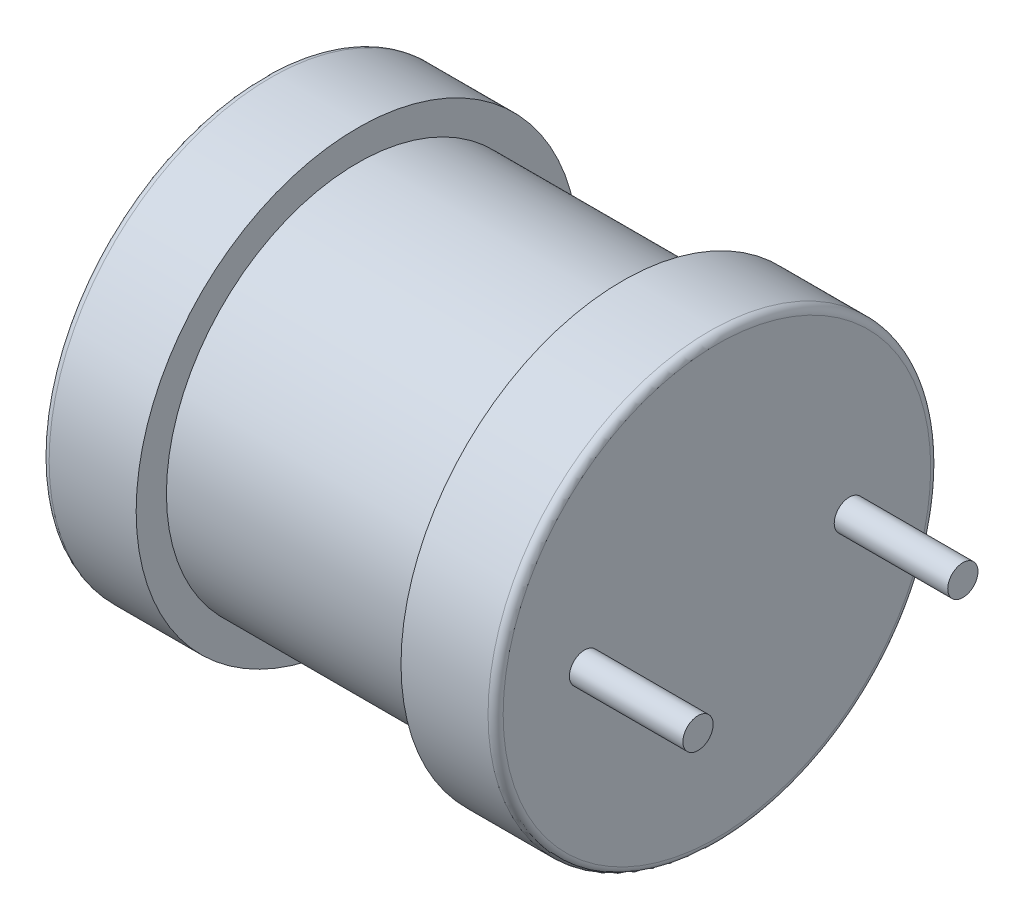
from build123d import *

# Parameters (mm, degrees)
SKETCH_2_R          = 0.4
EXTRUDE_2_DEPTH     = 3
CUT_EXTRUDE_1_DEPTH = 0.2


with BuildPart() as part:
    # Эскиз1 → Повернуть1 (revolve)
    with BuildSketch(Plane.XY):
        with BuildLine():
            Line((0, 0), (0, 5.65))
            ThreePointArc((0, 5.65), (0.058578644, 5.791421356), (0.2, 5.85))
            Line((0.2, 5.85), (2.5, 5.85))
            Line((2.5, 5.85), (2.5, 5.05))
            Line((2.5, 5.05), (9.5, 5.05))
            Line((9.5, 5.05), (9.5, 5.85))
            Line((9.5, 5.85), (11.8, 5.85))
            ThreePointArc((11.8, 5.85), (11.941421356, 5.791421356), (12, 5.65))
            Line((12, 5.65), (12, 0))
            Line((12, 0), (0, 0))
        make_face()
    revolve(axis=Axis((-21.888516746, 0, 0), (1, 0, 0)))

    # Эскиз2 → Бобышка-Вытянуть2 (add)
    with BuildSketch(Plane(origin=(12, 0, 0), x_dir=(0, 0, -1), z_dir=(1, 0, 0))):
        with Locations((3.5, 0)):
            Circle(SKETCH_2_R)
        with Locations((-3.5, 0)):
            Circle(SKETCH_2_R)
    extrude(amount=EXTRUDE_2_DEPTH)

    # Эскиз4 → Вырез-Вытянуть1 (cut)
    with BuildSketch(Plane.ZY):
        with BuildLine():
            Line((-3.579982895, -0.442704628), (-3.579982895, 1.098286583))
            Line((-3.579982895, 1.098286583), (-2.911355699, 1.098286583))
            add(Edge.make_bspline(
                [(-2.911355699, 1.098286583), (-2.895611576, 1.098163221), (-2.865140669, 1.097924469), (-2.820951561, 1.096234375), (-2.779705459, 1.092590975), (-2.741326525, 1.088651146), (-2.705821577, 1.082604034), (-2.673227246, 1.075668134), (-2.643493207, 1.067414308), (-2.61648653, 1.057665903), (-2.591430224, 1.046637043), (-2.56820492, 1.033029211), (-2.545845173, 1.018117929), (-2.525180832, 1.000599397), (-2.505666872, 0.981418226), (-2.487321379, 0.960313785), (-2.470415944, 0.937102929), (-2.449565115, 0.903883382), (-2.427196426, 0.85964194), (-2.408559795, 0.803022481), (-2.396543229, 0.74379646), (-2.395257422, 0.703322335), (-2.394605041, 0.682786949)],
                knots=[0, 0, 0, 0, 4.7234e-05, 9.1416e-05, 0.000132612, 0.00017144, 0.000207116, 0.000240599, 0.000271383, 0.000299603, 0.000326683, 0.00035337, 0.000380255, 0.00040721, 0.000434496, 0.000462287, 0.000490997, 0.000520544, 0.000579907, 0.00063916, 0.000698913, 0.000760455, 0.000760455, 0.000760455, 0.000760455], degree=3))
            add(Edge.make_bspline(
                [(-2.394605041, 0.682786949), (-2.394906586, 0.669605063), (-2.395502158, 0.643569933), (-2.400064303, 0.605291323), (-2.408319136, 0.568717651), (-2.418904333, 0.533528611), (-2.433392237, 0.500222775), (-2.450175846, 0.468119861), (-2.47096835, 0.438101822), (-2.494247858, 0.409369326), (-2.520943212, 0.382537746), (-2.551289248, 0.358575099), (-2.584985155, 0.337020651), (-2.622189626, 0.318469096), (-2.662474401, 0.301512094), (-2.706344942, 0.287857499), (-2.753624192, 0.276707475), (-2.786400366, 0.271308203), (-2.803313447, 0.268522084)],
                knots=[0, 0, 0, 0, 3.9543e-05, 7.81e-05, 0.000115399, 0.000151916, 0.000188153, 0.000224197, 0.000260414, 0.00029749, 0.000335033, 0.000373698, 0.00041326, 0.000454814, 0.000498268, 0.000544251, 0.00059247, 0.000643881, 0.000643881, 0.000643881, 0.000643881], degree=3))
            add(Edge.make_bspline(
                [(-2.803313447, 0.268522084), (-2.790907062, 0.262254652), (-2.767346889, 0.250352573), (-2.734727539, 0.231690216), (-2.707077245, 0.212621886), (-2.691058028, 0.198983656), (-2.683540893, 0.192583816)],
                knots=[0, 0, 0, 0, 4.1695e-05, 7.9181e-05, 0.000112663, 0.000142267, 0.000142267, 0.000142267, 0.000142267], degree=3))
            add(Edge.make_bspline(
                [(-2.683540893, 0.192583816), (-2.668983535, 0.178313351), (-2.639081689, 0.149000804), (-2.597875646, 0.099072948), (-2.557924972, 0.043495584), (-2.533651926, 0.003329634), (-2.521168822, -0.017326846)],
                knots=[0, 0, 0, 0, 6.1119e-05, 0.000125544, 0.000193904, 0.000266284, 0.000266284, 0.000266284, 0.000266284], degree=3))
            Line((-2.521168822, -0.017326846), (-2.268349952, -0.442704628))
            Line((-2.268349952, -0.442704628), (-2.517464516, -0.442704628))
            Line((-2.517464516, -0.442704628), (-2.709471033, -0.117343103))
            add(Edge.make_bspline(
                [(-2.709471033, -0.117343103), (-2.716374623, -0.105927402), (-2.729752647, -0.08380565), (-2.749076723, -0.051497895), (-2.768023344, -0.021753459), (-2.785596011, 0.00627777), (-2.802507852, 0.0320869), (-2.81859546, 0.055763585), (-2.833416095, 0.077618434), (-2.851773368, 0.103063166), (-2.873138185, 0.131217997), (-2.898069461, 0.160212157), (-2.921811427, 0.183328815), (-2.951050096, 0.205997157), (-2.987266612, 0.22719958), (-3.018051334, 0.236941511), (-3.032980406, 0.241665867)],
                knots=[0, 0, 0, 0, 4.0023e-05, 7.7558e-05, 0.00011293, 0.000145815, 0.000176809, 0.000205491, 0.000231692, 0.000256022, 0.000299612, 0.000337683, 0.000370649, 0.000398806, 0.000448581, 0.000495448, 0.000495448, 0.000495448, 0.000495448], degree=3))
            add(Edge.make_bspline(
                [(-3.032980406, 0.241665867), (-3.039244092, 0.242795423), (-3.053544273, 0.245374232), (-3.077825946, 0.247058456), (-3.107246172, 0.248846034), (-3.128567511, 0.24879395), (-3.140096582, 0.248765787)],
                knots=[0, 0, 0, 0, 1.9082e-05, 4.3564e-05, 7.293e-05, 0.000107505, 0.000107505, 0.000107505, 0.000107505], degree=3))
            Line((-3.140096582, 0.248765787), (-3.362663622, 0.248765787))
            Line((-3.362663622, 0.248765787), (-3.362663622, -0.442704628))
            Line((-3.362663622, -0.442704628), (-3.579982895, -0.442704628))
        make_face()
        with BuildLine():
            Line((-3.362663622, 0.426572465), (-2.949942218, 0.426572465))
            add(Edge.make_bspline(
                [(-2.949942218, 0.426572465), (-2.929246803, 0.426896264), (-2.890558667, 0.427501577), (-2.836459429, 0.43267031), (-2.790354841, 0.440883647), (-2.751333481, 0.45286376), (-2.718549379, 0.469496136), (-2.690036423, 0.489765794), (-2.666341798, 0.51515565), (-2.646630317, 0.543802698), (-2.631308179, 0.575327343), (-2.620255519, 0.608439362), (-2.613021361, 0.642860467), (-2.612293235, 0.666286996), (-2.611924314, 0.678156567)],
                knots=[0, 0, 0, 0, 6.2075e-05, 0.000116043, 0.000162843, 0.000202381, 0.000237999, 0.0002727, 0.000306763, 0.000341612, 0.000376678, 0.000411528, 0.000446156, 0.000481721, 0.000481721, 0.000481721, 0.000481721], degree=3))
            add(Edge.make_bspline(
                [(-2.611924314, 0.678156567), (-2.612211135, 0.686806375), (-2.612772932, 0.703748808), (-2.615718061, 0.728615596), (-2.621444089, 0.752244792), (-2.629005296, 0.774761303), (-2.639108603, 0.796000211), (-2.651110919, 0.816126096), (-2.665433388, 0.83502741), (-2.681838952, 0.85276173), (-2.70067552, 0.868898229), (-2.72219131, 0.882820527), (-2.746216626, 0.894651477), (-2.772779396, 0.90404131), (-2.801795941, 0.911551647), (-2.833431446, 0.916548033), (-2.867541235, 0.920163401), (-2.891177341, 0.920372432), (-2.903329703, 0.920479904)],
                knots=[0, 0, 0, 0, 2.596e-05, 5.0847e-05, 7.4957e-05, 9.8776e-05, 0.000121975, 0.000145375, 0.000168959, 0.000192986, 0.000217729, 0.000243158, 0.000269664, 0.000297884, 0.000327533, 0.000359454, 0.000393887, 0.000430324, 0.000430324, 0.000430324, 0.000430324], degree=3))
            Line((-2.903329703, 0.920479904), (-3.362663622, 0.920479904))
            Line((-3.362663622, 0.920479904), (-3.362663622, 0.426572465))
        make_face(mode=Mode.SUBTRACT)
        Polygon((-2.038991684, -0.442704628), (-2.038991684, 1.098286583), (-1.821672411, 1.098286583), (-1.821672411, -0.26489795), (-1.090689401, -0.26489795), (-1.090689401, -0.442704628), align=None)
        with BuildLine():
            Line((-0.85361383, -0.442704628), (-0.85361383, 1.098286583))
            Line((-0.85361383, 1.098286583), (-0.276668202, 1.098286583))
            add(Edge.make_bspline(
                [(-0.276668202, 1.098286583), (-0.262360905, 1.098231696), (-0.2344433, 1.098124598), (-0.193677825, 1.095446171), (-0.155069876, 1.091782639), (-0.118536339, 1.087060233), (-0.084235294, 1.080208119), (-0.052198707, 1.071907241), (-0.022259858, 1.062332445), (0.014335821, 1.047746931), (0.05650833, 1.025296724), (0.101679093, 0.991797473), (0.140979412, 0.951576888), (0.173317795, 0.905461711), (0.199961135, 0.856202004), (0.218850951, 0.804736212), (0.230928234, 0.752184871), (0.232298542, 0.716600837), (0.232982537, 0.698838941)],
                knots=[0, 0, 0, 0, 4.2913e-05, 8.3735e-05, 0.000122499, 0.000159258, 0.000194189, 0.000227357, 0.000258499, 0.000288421, 0.000345456, 0.000401268, 0.000456497, 0.000513374, 0.000569719, 0.000624023, 0.000677427, 0.000730651, 0.000730651, 0.000730651, 0.000730651], degree=3))
            add(Edge.make_bspline(
                [(0.232982537, 0.698838941), (0.232263514, 0.682313906), (0.230832401, 0.649423154), (0.219442343, 0.600973075), (0.201465346, 0.55392835), (0.176045364, 0.508860901), (0.143555441, 0.466595227), (0.103277214, 0.428561358), (0.055789477, 0.394677783), (0.020149932, 0.376616841), (0.001772117, 0.367303572)],
                knots=[0, 0, 0, 0, 4.9529e-05, 9.8581e-05, 0.000148514, 0.000200205, 0.000253244, 0.000307829, 0.000365819, 0.000427558, 0.000427558, 0.000427558, 0.000427558], degree=3))
            add(Edge.make_bspline(
                [(0.001772117, 0.367303572), (0.013140755, 0.363744701), (0.035398615, 0.356777036), (0.067396601, 0.344027187), (0.097432938, 0.329509659), (0.125573005, 0.313200596), (0.151626666, 0.294948968), (0.175520404, 0.274726321), (0.197419891, 0.252845596), (0.217285999, 0.229320103), (0.234736291, 0.204301233), (0.250387023, 0.178335799), (0.263310717, 0.151111121), (0.273903798, 0.122697881), (0.282167976, 0.093271648), (0.288102555, 0.062719243), (0.291485114, 0.031111784), (0.291993163, 0.009640192), (0.29225143, -0.001274854)],
                knots=[0, 0, 0, 0, 3.5728e-05, 6.995e-05, 0.000103223, 0.000135731, 0.000167418, 0.000198524, 0.00022952, 0.000260191, 0.000290765, 0.000320942, 0.000351042, 0.000381029, 0.000411814, 0.000442629, 0.000474298, 0.000507043, 0.000507043, 0.000507043, 0.000507043], degree=3))
            add(Edge.make_bspline(
                [(0.29225143, -0.001274854), (0.291719104, -0.018798809), (0.290663969, -0.053533419), (0.282190063, -0.104656925), (0.267869609, -0.153833428), (0.248158724, -0.200267805), (0.22467241, -0.243203222), (0.197979392, -0.281515492), (0.168760396, -0.314810382), (0.136192645, -0.342817336), (0.100486217, -0.366587044), (0.060632609, -0.386602693), (0.016939963, -0.404254577), (-0.03147975, -0.418355553), (-0.084604489, -0.429557351), (-0.143155205, -0.436835177), (-0.207221854, -0.442045124), (-0.25185787, -0.44247865), (-0.275124741, -0.442704628)],
                knots=[0, 0, 0, 0, 5.2551e-05, 0.000104163, 0.000154961, 0.000205872, 0.000255194, 0.000301524, 0.000345694, 0.000387714, 0.000430009, 0.000474049, 0.000521283, 0.000571193, 0.000625136, 0.000683987, 0.000748077, 0.000817859, 0.000817859, 0.000817859, 0.000817859], degree=3))
            Line((-0.275124741, -0.442704628), (-0.85361383, -0.442704628))
        make_face()
        with BuildLine():
            Line((-0.636294557, 0.446328763), (-0.318650335, 0.446328763))
            add(Edge.make_bspline(
                [(-0.318650335, 0.446328763), (-0.308256225, 0.446369886), (-0.288286792, 0.446448892), (-0.259481361, 0.44755048), (-0.232895329, 0.448490293), (-0.208631534, 0.450849149), (-0.186569771, 0.453159544), (-0.16679833, 0.456269696), (-0.149220367, 0.459774132), (-0.138457378, 0.463024759), (-0.133435045, 0.464541599)],
                knots=[0, 0, 0, 0, 3.1179e-05, 5.9903e-05, 8.6479e-05, 0.000110961, 0.000133017, 0.000153013, 0.000170994, 0.000186725, 0.000186725, 0.000186725, 0.000186725], degree=3))
            add(Edge.make_bspline(
                [(-0.133435045, 0.464541599), (-0.121634362, 0.46867538), (-0.098885116, 0.476644442), (-0.068398997, 0.494742985), (-0.042433686, 0.516461148), (-0.021058762, 0.542182421), (-0.004633193, 0.571769154), (0.007545893, 0.60460779), (0.014214212, 0.641157382), (0.015167116, 0.66650324), (0.015663264, 0.679700028)],
                knots=[0, 0, 0, 0, 3.7433e-05, 7.2164e-05, 0.00010568, 0.000138565, 0.000171876, 0.000206742, 0.000243189, 0.000282778, 0.000282778, 0.000282778, 0.000282778], degree=3))
            add(Edge.make_bspline(
                [(0.015663264, 0.679700028), (0.015264328, 0.692382994), (0.014486848, 0.717100634), (0.007960599, 0.752994932), (-0.003332832, 0.786387984), (-0.018627232, 0.817272467), (-0.037994005, 0.844748651), (-0.061108924, 0.868371737), (-0.088798966, 0.88622975), (-0.114680862, 0.897369615), (-0.137959575, 0.904338652), (-0.158758288, 0.908461944), (-0.182350232, 0.912094974), (-0.208813041, 0.915183656), (-0.238156726, 0.917580758), (-0.2704717, 0.919485096), (-0.305681039, 0.920293632), (-0.330071756, 0.920416268), (-0.342728322, 0.920479904)],
                knots=[0, 0, 0, 0, 3.8031e-05, 7.4117e-05, 0.000108967, 0.000143479, 0.00017714, 0.000209445, 0.000241979, 0.000275298, 0.000293659, 0.000314788, 0.000338845, 0.000365264, 0.000394694, 0.00042716, 0.000462363, 0.000500333, 0.000500333, 0.000500333, 0.000500333], degree=3))
            Line((-0.342728322, 0.920479904), (-0.636294557, 0.920479904))
            Line((-0.636294557, 0.920479904), (-0.636294557, 0.446328763))
        make_face(mode=Mode.SUBTRACT)
        with BuildLine():
            Line((-0.636294557, -0.26489795), (-0.271729128, -0.26489795))
            add(Edge.make_bspline(
                [(-0.271729128, -0.26489795), (-0.257220265, -0.264731264), (-0.23056348, -0.264425015), (-0.194102207, -0.263464298), (-0.164630226, -0.261117625), (-0.147420146, -0.258590858), (-0.13991758, -0.257489338)],
                knots=[0, 0, 0, 0, 4.353e-05, 7.9977e-05, 0.000109406, 0.000132151, 0.000132151, 0.000132151, 0.000132151], degree=3))
            add(Edge.make_bspline(
                [(-0.13991758, -0.257489338), (-0.129161127, -0.255228441), (-0.108333853, -0.250850759), (-0.078972393, -0.24108023), (-0.052051647, -0.229887567), (-0.028041475, -0.215662937), (-0.005808631, -0.199270025), (0.013513364, -0.178794493), (0.03130984, -0.155530823), (0.046728919, -0.128908198), (0.059197483, -0.099456481), (0.068726993, -0.067630723), (0.073803104, -0.033542511), (0.074550494, -0.010139103), (0.074932156, 0.001812067)],
                knots=[0, 0, 0, 0, 3.2948e-05, 6.3795e-05, 9.2696e-05, 0.000120226, 0.00014733, 0.000175273, 0.000204352, 0.000235061, 0.000267284, 0.000300105, 0.000334464, 0.00037032, 0.00037032, 0.00037032, 0.00037032], degree=3))
            add(Edge.make_bspline(
                [(0.074932156, 0.001812067), (0.074506944, 0.015843457), (0.073677735, 0.0432061), (0.065795828, 0.082746504), (0.052776206, 0.119420721), (0.034448373, 0.15272085), (0.011968328, 0.182671448), (-0.015230256, 0.208077725), (-0.046944005, 0.228238863), (-0.083270389, 0.244061454), (-0.125728655, 0.255318955), (-0.175490991, 0.262956487), (-0.233353363, 0.267884804), (-0.274701714, 0.268300559), (-0.296733192, 0.268522084)],
                knots=[0, 0, 0, 0, 4.2055e-05, 8.2011e-05, 0.000120385, 0.000158374, 0.000195603, 0.000232297, 0.000269373, 0.0003078, 0.000350713, 0.000400752, 0.000458688, 0.000524766, 0.000524766, 0.000524766, 0.000524766], degree=3))
            Line((-0.296733192, 0.268522084), (-0.636294557, 0.268522084))
            Line((-0.636294557, 0.268522084), (-0.636294557, -0.26489795))
        make_face(mode=Mode.SUBTRACT)
        with BuildLine():
            Line((1.18128482, -0.442704628), (0.983721845, -0.442704628))
            Line((0.983721845, -0.442704628), (0.983721845, 0.758107834))
            add(Edge.make_bspline(
                [(0.983721845, 0.758107834), (0.972346151, 0.747137377), (0.948703019, 0.724336484), (0.908736801, 0.692067528), (0.864129394, 0.659361573), (0.815460054, 0.62791114), (0.765849895, 0.59830395), (0.717908063, 0.571676834), (0.672434969, 0.549143834), (0.642481596, 0.5368227), (0.628108488, 0.530910412)],
                knots=[0, 0, 0, 0, 4.7391e-05, 9.8497e-05, 0.000153942, 0.000213277, 0.000272253, 0.000327241, 0.00037777, 0.000424383, 0.000424383, 0.000424383, 0.000424383], degree=3))
            Line((0.628108488, 0.530910412), (0.628108488, 0.71303878))
            add(Edge.make_bspline(
                [(0.628108488, 0.71303878), (0.652795785, 0.725752787), (0.701452986, 0.750811343), (0.770195088, 0.794090913), (0.834373236, 0.841007749), (0.892925026, 0.891551463), (0.945412974, 0.943216212), (0.989645331, 0.995347974), (1.026656152, 1.046035822), (1.045225183, 1.081384974), (1.054103655, 1.098286583)],
                knots=[0, 0, 0, 0, 8.3274e-05, 0.000164129, 0.000243405, 0.000321553, 0.000395986, 0.000464089, 0.000526529, 0.000583737, 0.000583737, 0.000583737, 0.000583737], degree=3))
            Line((1.054103655, 1.098286583), (1.18128482, 1.098286583))
            Line((1.18128482, 1.098286583), (1.18128482, -0.442704628))
        make_face()
        with BuildLine():
            Line((1.67519226, -0.027822379), (1.872755236, -0.008066082))
            add(Edge.make_bspline(
                [(1.872755236, -0.008066082), (1.875388987, -0.019936835), (1.8804851, -0.042905863), (1.890290643, -0.075811382), (1.900647451, -0.106355061), (1.913486725, -0.133853712), (1.926015065, -0.159431916), (1.940737763, -0.182032805), (1.956469251, -0.202246068), (1.973500352, -0.219996647), (1.992027319, -0.235282063), (2.011803146, -0.248657626), (2.033246075, -0.259828023), (2.056191932, -0.268672255), (2.080447458, -0.275831735), (2.106144471, -0.281088812), (2.133418851, -0.284220518), (2.152113224, -0.284507312), (2.161691088, -0.284654248)],
                knots=[0, 0, 0, 0, 3.6465e-05, 7.0557e-05, 0.000102971, 0.000133092, 0.000161532, 0.000188333, 0.000213837, 0.000238288, 0.000261963, 0.000285764, 0.000309789, 0.000334323, 0.000359426, 0.00038558, 0.00041292, 0.000441643, 0.000441643, 0.000441643, 0.000441643], degree=3))
            add(Edge.make_bspline(
                [(2.161691088, -0.284654248), (2.172925581, -0.284494071), (2.194866566, -0.284181246), (2.2268382, -0.279487671), (2.257264848, -0.273042946), (2.285712402, -0.262937249), (2.312576979, -0.250586219), (2.337705529, -0.235322965), (2.361270057, -0.217400086), (2.382805769, -0.196695668), (2.402065103, -0.173920149), (2.419218245, -0.149863388), (2.433401589, -0.124320115), (2.445356013, -0.097650116), (2.454179941, -0.069422417), (2.460639768, -0.039989001), (2.464861299, -0.009216759), (2.465247209, 0.011778974), (2.465444163, 0.022494441)],
                knots=[0, 0, 0, 0, 3.367e-05, 6.5758e-05, 9.6762e-05, 0.000126831, 0.00015611, 0.000185333, 0.000214845, 0.000244756, 0.000274757, 0.000304218, 0.000333242, 0.000362266, 0.000391749, 0.000421782, 0.000452605, 0.000484733, 0.000484733, 0.000484733, 0.000484733], degree=3))
            add(Edge.make_bspline(
                [(2.465444163, 0.022494441), (2.465212684, 0.032691845), (2.464759813, 0.052642252), (2.461036849, 0.081925168), (2.454540358, 0.109722555), (2.445534669, 0.136195284), (2.434027247, 0.161304493), (2.420195665, 0.18525781), (2.403278506, 0.207530298), (2.384236752, 0.228361184), (2.363467754, 0.247552405), (2.340739275, 0.26387701), (2.316820373, 0.277965675), (2.29142599, 0.289341722), (2.264661564, 0.298370955), (2.23655261, 0.304860442), (2.206963985, 0.308585022), (2.186808582, 0.309037972), (2.176508311, 0.309269448)],
                knots=[0, 0, 0, 0, 3.0585e-05, 5.9838e-05, 8.8367e-05, 0.00011609, 0.00014358, 0.00017111, 0.000198893, 0.000227299, 0.000255706, 0.000283553, 0.000311084, 0.000338854, 0.00036687, 0.0003957, 0.000425258, 0.000456152, 0.000456152, 0.000456152, 0.000456152], degree=3))
            add(Edge.make_bspline(
                [(2.176508311, 0.309269448), (2.167439548, 0.309029188), (2.148193519, 0.3085193), (2.117816844, 0.304017183), (2.084169532, 0.297713163), (2.060918279, 0.291526702), (2.048709761, 0.288278382)],
                knots=[0, 0, 0, 0, 2.7193e-05, 5.771e-05, 9.1976e-05, 0.00012986, 0.00012986, 0.00012986, 0.00012986], degree=3))
            Line((2.048709761, 0.288278382), (2.069083443, 0.46608506))
            add(Edge.make_bspline(
                [(2.069083443, 0.46608506), (2.07442902, 0.465500935), (2.083872816, 0.464468986), (2.093364236, 0.464089079), (2.097483121, 0.463924215)],
                knots=[0, 0, 0, 0, 1.6126e-05, 2.8489e-05, 2.8489e-05, 2.8489e-05, 2.8489e-05], degree=3))
            add(Edge.make_bspline(
                [(2.097483121, 0.463924215), (2.115652372, 0.46461791), (2.151294732, 0.465978722), (2.203254384, 0.477285926), (2.252496894, 0.495088755), (2.290539914, 0.516330112), (2.318751333, 0.536308762), (2.336540886, 0.554322349), (2.352579086, 0.573438404), (2.364544894, 0.595365211), (2.374882614, 0.618662973), (2.381284223, 0.644249451), (2.385952801, 0.671502704), (2.386260792, 0.690379048), (2.386418973, 0.70007371)],
                knots=[0, 0, 0, 0, 5.4456e-05, 0.000106825, 0.000158781, 0.000211011, 0.000237066, 0.000262169, 0.000286756, 0.000311644, 0.000336815, 0.000363023, 0.000390529, 0.000419573, 0.000419573, 0.000419573, 0.000419573], degree=3))
            add(Edge.make_bspline(
                [(2.386418973, 0.70007371), (2.386272983, 0.707904415), (2.38598747, 0.723219066), (2.38280672, 0.745671961), (2.377546149, 0.76694677), (2.370435965, 0.78727065), (2.361117362, 0.806537087), (2.349561564, 0.824722495), (2.336358672, 0.842195778), (2.320773125, 0.858054033), (2.304082356, 0.87294258), (2.285677722, 0.885481789), (2.266435146, 0.896621034), (2.245675986, 0.905038441), (2.223912736, 0.911958921), (2.200959361, 0.916808514), (2.176807484, 0.920065341), (2.160261712, 0.920339772), (2.151812939, 0.920479904)],
                knots=[0, 0, 0, 0, 2.3479e-05, 4.5918e-05, 6.7855e-05, 8.9139e-05, 0.000110401, 0.000131898, 0.000153694, 0.000175962, 0.000198497, 0.000220675, 0.000242653, 0.000265069, 0.00028772, 0.000311091, 0.000335366, 0.000360695, 0.000360695, 0.000360695, 0.000360695], degree=3))
            add(Edge.make_bspline(
                [(2.151812939, 0.920479904), (2.135278903, 0.919835215), (2.10334923, 0.918590225), (2.057635013, 0.907071479), (2.016209679, 0.88843265), (1.985540359, 0.866574506), (1.963762445, 0.845676885), (1.948886976, 0.827963741), (1.935581712, 0.808403264), (1.923808943, 0.787002427), (1.913727723, 0.763675163), (1.904639783, 0.738710462), (1.897604875, 0.71170864), (1.894238094, 0.692999039), (1.892511533, 0.683404334)],
                knots=[0, 0, 0, 0, 4.9529e-05, 9.5649e-05, 0.000140408, 0.00018512, 0.000207826, 0.000230829, 0.000254375, 0.000278691, 0.000303985, 0.000330543, 0.000358322, 0.000387563, 0.000387563, 0.000387563, 0.000387563], degree=3))
            Line((1.892511533, 0.683404334), (1.694948557, 0.703160631))
            add(Edge.make_bspline(
                [(1.694948557, 0.703160631), (1.698039032, 0.718436415), (1.704101241, 0.748401069), (1.716451936, 0.791678193), (1.731513455, 0.832303089), (1.74959734, 0.8700895), (1.769849251, 0.905489639), (1.793211298, 0.938083606), (1.81913576, 0.968065177), (1.847668684, 0.995342903), (1.87842272, 1.019704964), (1.911242967, 1.040720438), (1.945860083, 1.05853408), (1.982306477, 1.072895028), (2.020553293, 1.084572654), (2.060709341, 1.09230911), (2.102592861, 1.097542433), (2.131113831, 1.098035481), (2.145639096, 1.098286583)],
                knots=[0, 0, 0, 0, 4.6742e-05, 9.1688e-05, 0.000134863, 0.000176563, 0.000217226, 0.000257058, 0.000296668, 0.000335968, 0.000375308, 0.000414184, 0.000452702, 0.000491911, 0.000531561, 0.000572485, 0.000614451, 0.000658003, 0.000658003, 0.000658003, 0.000658003], degree=3))
            add(Edge.make_bspline(
                [(2.145639096, 1.098286583), (2.16574552, 1.097634581), (2.205281251, 1.096352534), (2.263350026, 1.086170366), (2.318892504, 1.069461226), (2.371461738, 1.046299377), (2.420153301, 1.017996209), (2.463241322, 0.984076585), (2.50014977, 0.945127309), (2.530161783, 0.901574208), (2.553927086, 0.855203171), (2.571512696, 0.807068023), (2.582020363, 0.757224175), (2.583326757, 0.723479903), (2.583981948, 0.706556245)],
                knots=[0, 0, 0, 0, 6.0291e-05, 0.000118551, 0.000176266, 0.000233907, 0.000290502, 0.000344787, 0.000397851, 0.000450857, 0.000502905, 0.000553779, 0.00060421, 0.000654949, 0.000654949, 0.000654949, 0.000654949], degree=3))
            add(Edge.make_bspline(
                [(2.583981948, 0.706556245), (2.583317715, 0.690558362), (2.582006218, 0.65897131), (2.57190924, 0.612785444), (2.554847355, 0.56902953), (2.531786093, 0.527550047), (2.501881295, 0.489244024), (2.4652151, 0.455109865), (2.42237407, 0.424820959), (2.390268342, 0.409055919), (2.373762595, 0.400951017)],
                knots=[0, 0, 0, 0, 4.7968e-05, 9.471e-05, 0.00014103, 0.000188433, 0.000236598, 0.000286171, 0.000338241, 0.000393335, 0.000393335, 0.000393335, 0.000393335], degree=3))
            add(Edge.make_bspline(
                [(2.373762595, 0.400951017), (2.384828597, 0.39815707), (2.406503666, 0.392684544), (2.43763398, 0.381345624), (2.46689997, 0.368070602), (2.494691148, 0.353035077), (2.520200684, 0.335253132), (2.544307868, 0.31581059), (2.566101392, 0.293771087), (2.586212656, 0.269920147), (2.604511436, 0.244507377), (2.619910039, 0.21703844), (2.633198586, 0.188235445), (2.644529796, 0.157889487), (2.652672378, 0.125766575), (2.658494581, 0.092115565), (2.66233676, 0.057053372), (2.662781489, 0.03310306), (2.663007139, 0.02095098)],
                knots=[0, 0, 0, 0, 3.4222e-05, 6.703e-05, 9.922e-05, 0.000130583, 0.000161664, 0.000192375, 0.000223371, 0.000254477, 0.000285912, 0.000317156, 0.000348784, 0.000381012, 0.000414181, 0.000448031, 0.000483417, 0.000519863, 0.000519863, 0.000519863, 0.000519863], degree=3))
            add(Edge.make_bspline(
                [(2.663007139, 0.02095098), (2.662631125, 0.004360468), (2.661892136, -0.028245212), (2.654886504, -0.076143699), (2.643437728, -0.122036889), (2.627594158, -0.166080626), (2.607517847, -0.208454661), (2.582325389, -0.248561025), (2.55276343, -0.286725727), (2.519294131, -0.322583355), (2.48262531, -0.355537619), (2.442804373, -0.38407286), (2.400619175, -0.408305437), (2.356001065, -0.428066984), (2.309068327, -0.443592726), (2.25977427, -0.454722074), (2.207966356, -0.461262907), (2.172617038, -0.462056331), (2.154591168, -0.462460926)],
                knots=[0, 0, 0, 0, 4.9746e-05, 9.7768e-05, 0.00014486, 0.000191436, 0.000237966, 0.000285249, 0.000333224, 0.000382586, 0.000432217, 0.000480876, 0.000529273, 0.000577917, 0.000627019, 0.000677343, 0.000729301, 0.000783365, 0.000783365, 0.000783365, 0.000783365], degree=3))
            add(Edge.make_bspline(
                [(2.154591168, -0.462460926), (2.138414446, -0.462156222), (2.106567976, -0.461556364), (2.059951319, -0.455306864), (2.015290139, -0.446438106), (1.97293759, -0.43276585), (1.932401712, -0.416092755), (1.894369033, -0.394762045), (1.858155698, -0.370275216), (1.824441566, -0.341932673), (1.793413871, -0.310649915), (1.765733455, -0.276889639), (1.741964094, -0.240726805), (1.721006743, -0.202702476), (1.704067783, -0.162099876), (1.690878121, -0.119267604), (1.680820826, -0.074364622), (1.677088863, -0.043505262), (1.67519226, -0.027822379)],
                knots=[0, 0, 0, 0, 4.85e-05, 9.548e-05, 0.000140886, 0.000184917, 0.000228775, 0.00027216, 0.000315484, 0.000359751, 0.000404062, 0.000447501, 0.00049048, 0.000533717, 0.000577575, 0.000622195, 0.000668032, 0.000715399, 0.000715399, 0.000715399, 0.000715399], degree=3))
        make_face()
        with BuildLine():
            Line((3.55204053, -0.442704628), (3.354477554, -0.442704628))
            Line((3.354477554, -0.442704628), (3.354477554, 0.758107834))
            add(Edge.make_bspline(
                [(3.354477554, 0.758107834), (3.34310186, 0.747137377), (3.319458728, 0.724336484), (3.27949251, 0.692067528), (3.234885103, 0.659361573), (3.186215763, 0.62791114), (3.136605604, 0.59830395), (3.088663773, 0.571676834), (3.043190678, 0.549143834), (3.013237305, 0.5368227), (2.998864198, 0.530910412)],
                knots=[0, 0, 0, 0, 4.7391e-05, 9.8497e-05, 0.000153942, 0.000213277, 0.000272253, 0.000327241, 0.00037777, 0.000424383, 0.000424383, 0.000424383, 0.000424383], degree=3))
            Line((2.998864198, 0.530910412), (2.998864198, 0.71303878))
            add(Edge.make_bspline(
                [(2.998864198, 0.71303878), (3.023551494, 0.725752787), (3.072208695, 0.750811343), (3.140950798, 0.794090913), (3.205128945, 0.841007749), (3.263680735, 0.891551463), (3.316168684, 0.943216212), (3.36040104, 0.995347974), (3.397411861, 1.046035822), (3.415980892, 1.081384974), (3.424859364, 1.098286583)],
                knots=[0, 0, 0, 0, 8.3274e-05, 0.000164129, 0.000243405, 0.000321553, 0.000395986, 0.000464089, 0.000526529, 0.000583737, 0.000583737, 0.000583737, 0.000583737], degree=3))
            Line((3.424859364, 1.098286583), (3.55204053, 1.098286583))
            Line((3.55204053, 1.098286583), (3.55204053, -0.442704628))
        make_face()
        Polygon((4.638636896, -0.442704628), (4.638636896, -0.067334974), (3.966922779, -0.067334974), (3.966922779, 0.130228001), (4.697905789, 1.078530285), (4.836199872, 1.078530285), (4.836199872, 0.130228001), (5.033762848, 0.130228001), (5.033762848, -0.067334974), (4.836199872, -0.067334974), (4.836199872, -0.442704628), align=None)
        Polygon((4.638636896, 0.130228001), (4.638636896, 0.685256486), (4.210789577, 0.130228001), align=None, mode=Mode.SUBTRACT)
    extrude(amount=-CUT_EXTRUDE_1_DEPTH, mode=Mode.SUBTRACT)


solid = part.part
